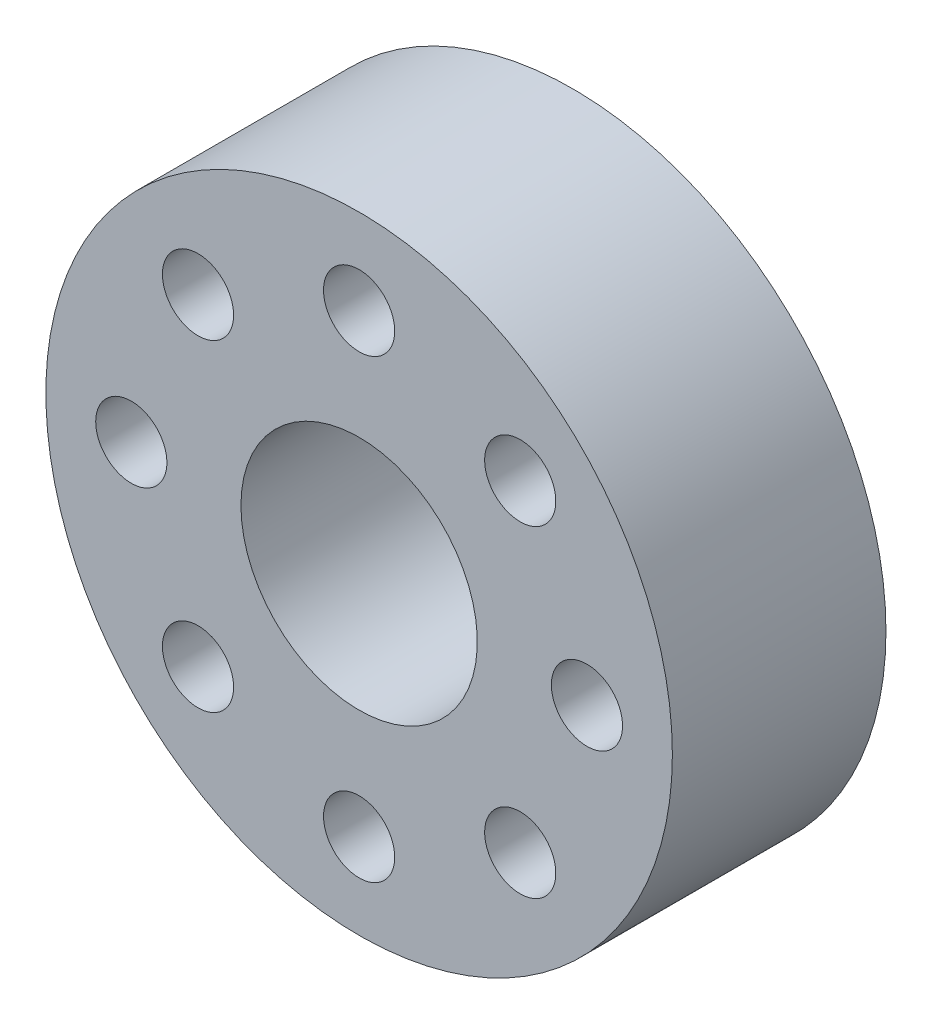
from build123d import *

# Parameters (mm, degrees)
SKETCH2_R           = 11
BOSS_EXTRUDE1_DEPTH = 7.5
SKETCH3_R           = 4.15
SKETCH3_R_2         = 1.25
CUT_EXTRUDE1_DEPTH  = 8.5


with BuildPart() as part:
    # Sketch2 → Boss-Extrude1 (new body)
    with BuildSketch(Plane.XY):
        Circle(SKETCH2_R)
    extrude(amount=BOSS_EXTRUDE1_DEPTH)

    # Sketch3 → Cut-Extrude1 (cut, through all)
    with BuildSketch(Plane(origin=(0, 0, 0), x_dir=(-1, 0, 0), z_dir=(0, 0, -1))):
        Circle(SKETCH3_R)
        with Locations((8, 0)):
            Circle(SKETCH3_R_2)
        with Locations((5.656854249, -5.656854249)):
            Circle(SKETCH3_R_2)
        with Locations((0, -8)):
            Circle(SKETCH3_R_2)
        with Locations((-5.656854249, -5.656854249)):
            Circle(SKETCH3_R_2)
        with Locations((-8, 0)):
            Circle(SKETCH3_R_2)
        with Locations((-5.656854249, 5.656854249)):
            Circle(SKETCH3_R_2)
        with Locations((0, 8)):
            Circle(SKETCH3_R_2)
        with Locations((5.656854249, 5.656854249)):
            Circle(SKETCH3_R_2)
    extrude(amount=-CUT_EXTRUDE1_DEPTH, mode=Mode.SUBTRACT)


solid = part.part
